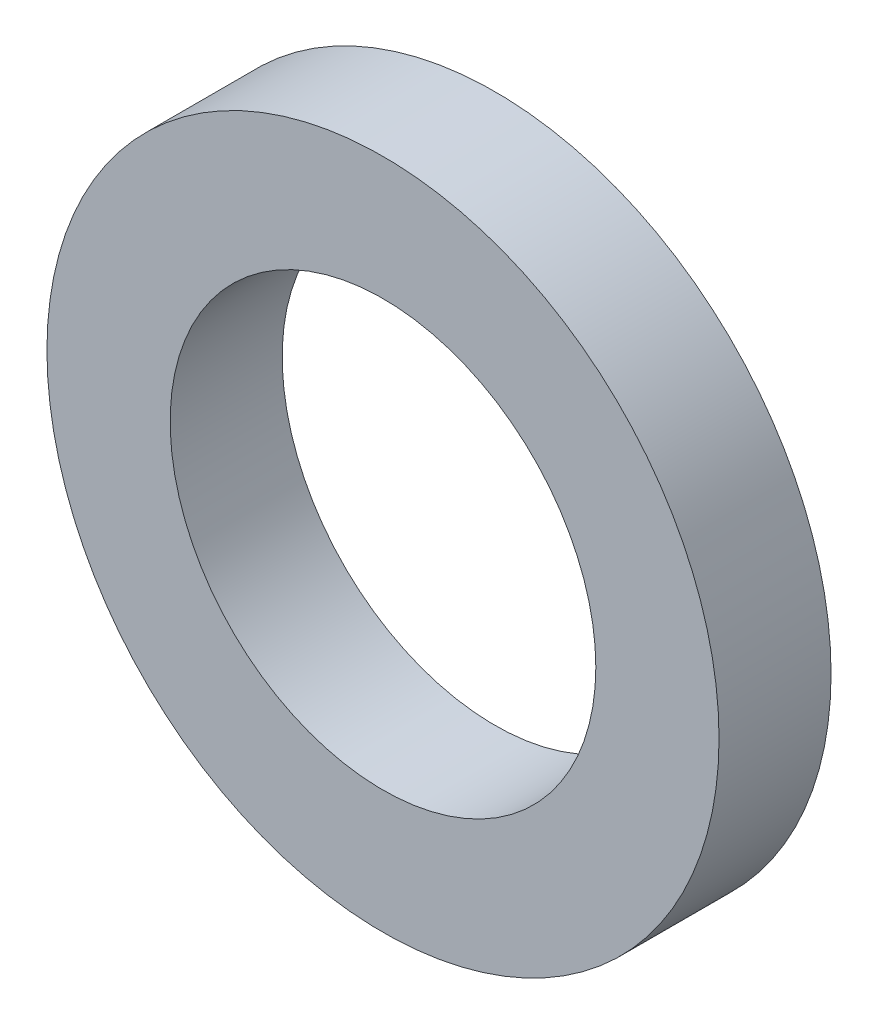
from build123d import *

# Parameters (mm, degrees)
SKETCH_1_R      = 3
SKETCH_1_R_2    = 1.9
EXTRUDE_1_DEPTH = 1


with BuildPart() as part:
    # Эскиз1 → Бобышка-Вытянуть1 (new body)
    with BuildSketch(Plane.XY):
        Circle(SKETCH_1_R)
        Circle(SKETCH_1_R_2, mode=Mode.SUBTRACT)
    extrude(amount=EXTRUDE_1_DEPTH)


solid = part.part
